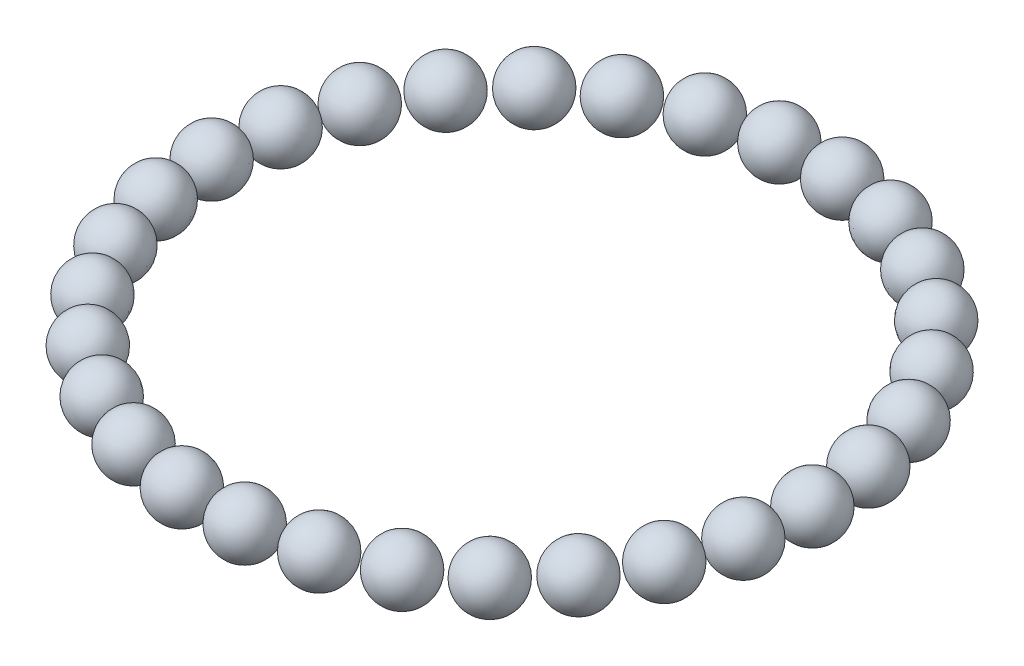
from build123d import *

# Parameters (mm, degrees)
CIRPATTERN2_COUNT = 30


with BuildPart() as part:
    # Sketch1 → Revolve1 (revolve)
    with BuildSketch(Plane.XY):
        with BuildLine():
            Line((0, 1.25), (0, -1.25))
            ThreePointArc((0, -1.25), (1.25, 0), (0, 1.25))
        make_face()
    revolve(axis=Axis((0, 1.25, 0), (0, -1, 0)))


with BuildPart() as cirpattern2_1:
    # CirPattern2: pattern copy
    add(part.part.rotate(Axis((12.7, 0, 0), (0, 1, 0)), 1 * 360 / CIRPATTERN2_COUNT))


with BuildPart() as cirpattern2_2:
    # CirPattern2: pattern copy
    add(part.part.rotate(Axis((12.7, 0, 0), (0, 1, 0)), 2 * 360 / CIRPATTERN2_COUNT))


with BuildPart() as cirpattern2_3:
    # CirPattern2: pattern copy
    add(part.part.rotate(Axis((12.7, 0, 0), (0, 1, 0)), 3 * 360 / CIRPATTERN2_COUNT))


with BuildPart() as cirpattern2_4:
    # CirPattern2: pattern copy
    add(part.part.rotate(Axis((12.7, 0, 0), (0, 1, 0)), 4 * 360 / CIRPATTERN2_COUNT))


with BuildPart() as cirpattern2_5:
    # CirPattern2: pattern copy
    add(part.part.rotate(Axis((12.7, 0, 0), (0, 1, 0)), 5 * 360 / CIRPATTERN2_COUNT))


with BuildPart() as cirpattern2_6:
    # CirPattern2: pattern copy
    add(part.part.rotate(Axis((12.7, 0, 0), (0, 1, 0)), 6 * 360 / CIRPATTERN2_COUNT))


with BuildPart() as cirpattern2_7:
    # CirPattern2: pattern copy
    add(part.part.rotate(Axis((12.7, 0, 0), (0, 1, 0)), 7 * 360 / CIRPATTERN2_COUNT))


with BuildPart() as cirpattern2_8:
    # CirPattern2: pattern copy
    add(part.part.rotate(Axis((12.7, 0, 0), (0, 1, 0)), 8 * 360 / CIRPATTERN2_COUNT))


with BuildPart() as cirpattern2_9:
    # CirPattern2: pattern copy
    add(part.part.rotate(Axis((12.7, 0, 0), (0, 1, 0)), 9 * 360 / CIRPATTERN2_COUNT))


with BuildPart() as cirpattern2_10:
    # CirPattern2: pattern copy
    add(part.part.rotate(Axis((12.7, 0, 0), (0, 1, 0)), 10 * 360 / CIRPATTERN2_COUNT))


with BuildPart() as cirpattern2_11:
    # CirPattern2: pattern copy
    add(part.part.rotate(Axis((12.7, 0, 0), (0, 1, 0)), 11 * 360 / CIRPATTERN2_COUNT))


with BuildPart() as cirpattern2_12:
    # CirPattern2: pattern copy
    add(part.part.rotate(Axis((12.7, 0, 0), (0, 1, 0)), 12 * 360 / CIRPATTERN2_COUNT))


with BuildPart() as cirpattern2_13:
    # CirPattern2: pattern copy
    add(part.part.rotate(Axis((12.7, 0, 0), (0, 1, 0)), 13 * 360 / CIRPATTERN2_COUNT))


with BuildPart() as cirpattern2_14:
    # CirPattern2: pattern copy
    add(part.part.rotate(Axis((12.7, 0, 0), (0, 1, 0)), 14 * 360 / CIRPATTERN2_COUNT))


with BuildPart() as cirpattern2_15:
    # CirPattern2: pattern copy
    add(part.part.rotate(Axis((12.7, 0, 0), (0, 1, 0)), 15 * 360 / CIRPATTERN2_COUNT))


with BuildPart() as cirpattern2_16:
    # CirPattern2: pattern copy
    add(part.part.rotate(Axis((12.7, 0, 0), (0, 1, 0)), 16 * 360 / CIRPATTERN2_COUNT))


with BuildPart() as cirpattern2_17:
    # CirPattern2: pattern copy
    add(part.part.rotate(Axis((12.7, 0, 0), (0, 1, 0)), 17 * 360 / CIRPATTERN2_COUNT))


with BuildPart() as cirpattern2_18:
    # CirPattern2: pattern copy
    add(part.part.rotate(Axis((12.7, 0, 0), (0, 1, 0)), 18 * 360 / CIRPATTERN2_COUNT))


with BuildPart() as cirpattern2_19:
    # CirPattern2: pattern copy
    add(part.part.rotate(Axis((12.7, 0, 0), (0, 1, 0)), 19 * 360 / CIRPATTERN2_COUNT))


with BuildPart() as cirpattern2_20:
    # CirPattern2: pattern copy
    add(part.part.rotate(Axis((12.7, 0, 0), (0, 1, 0)), 20 * 360 / CIRPATTERN2_COUNT))


with BuildPart() as cirpattern2_21:
    # CirPattern2: pattern copy
    add(part.part.rotate(Axis((12.7, 0, 0), (0, 1, 0)), 21 * 360 / CIRPATTERN2_COUNT))


with BuildPart() as cirpattern2_22:
    # CirPattern2: pattern copy
    add(part.part.rotate(Axis((12.7, 0, 0), (0, 1, 0)), 22 * 360 / CIRPATTERN2_COUNT))


with BuildPart() as cirpattern2_23:
    # CirPattern2: pattern copy
    add(part.part.rotate(Axis((12.7, 0, 0), (0, 1, 0)), 23 * 360 / CIRPATTERN2_COUNT))


with BuildPart() as cirpattern2_24:
    # CirPattern2: pattern copy
    add(part.part.rotate(Axis((12.7, 0, 0), (0, 1, 0)), 24 * 360 / CIRPATTERN2_COUNT))


with BuildPart() as cirpattern2_25:
    # CirPattern2: pattern copy
    add(part.part.rotate(Axis((12.7, 0, 0), (0, 1, 0)), 25 * 360 / CIRPATTERN2_COUNT))


with BuildPart() as cirpattern2_26:
    # CirPattern2: pattern copy
    add(part.part.rotate(Axis((12.7, 0, 0), (0, 1, 0)), 26 * 360 / CIRPATTERN2_COUNT))


with BuildPart() as cirpattern2_27:
    # CirPattern2: pattern copy
    add(part.part.rotate(Axis((12.7, 0, 0), (0, 1, 0)), 27 * 360 / CIRPATTERN2_COUNT))


with BuildPart() as cirpattern2_28:
    # CirPattern2: pattern copy
    add(part.part.rotate(Axis((12.7, 0, 0), (0, 1, 0)), 28 * 360 / CIRPATTERN2_COUNT))


with BuildPart() as cirpattern2_29:
    # CirPattern2: pattern copy
    add(part.part.rotate(Axis((12.7, 0, 0), (0, 1, 0)), 29 * 360 / CIRPATTERN2_COUNT))


solid = Compound([part.part, cirpattern2_1.part, cirpattern2_2.part, cirpattern2_3.part, cirpattern2_4.part, cirpattern2_5.part, cirpattern2_6.part, cirpattern2_7.part, cirpattern2_8.part, cirpattern2_9.part, cirpattern2_10.part, cirpattern2_11.part, cirpattern2_12.part, cirpattern2_13.part, cirpattern2_14.part, cirpattern2_15.part, cirpattern2_16.part, cirpattern2_17.part, cirpattern2_18.part, cirpattern2_19.part, cirpattern2_20.part, cirpattern2_21.part, cirpattern2_22.part, cirpattern2_23.part, cirpattern2_24.part, cirpattern2_25.part, cirpattern2_26.part, cirpattern2_27.part, cirpattern2_28.part, cirpattern2_29.part])
